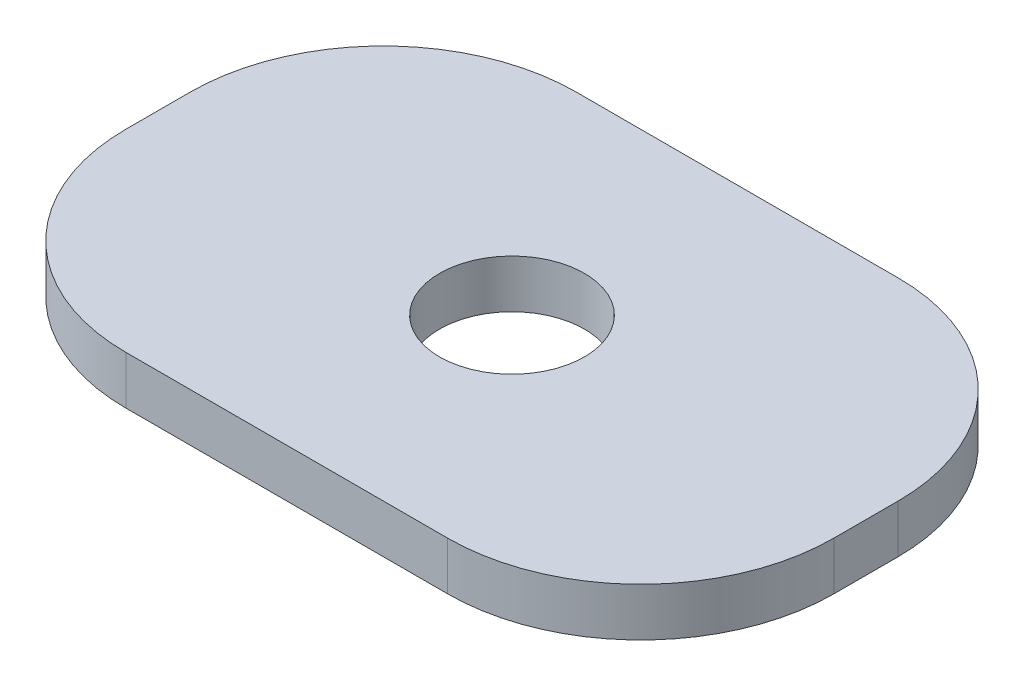
from build123d import *

# Parameters (mm, degrees)
SKETCH1_W           = 69.85
SKETCH1_H           = 44.45
BOSS_EXTRUDE1_DEPTH = 4.7625
SKETCH2_R           = 7.14375
CUT_EXTRUDE1_DEPTH  = 5.7625
FILLET1_R           = 19.05
FILLET2_R           = 19.05


with BuildPart() as part:
    # Sketch1 → Boss-Extrude1 (new body)
    with BuildSketch(Plane(origin=(0, 0, 0), x_dir=(1, 0, 0), z_dir=(0, 1, 0))):
        Rectangle(SKETCH1_W, SKETCH1_H)
    extrude(amount=BOSS_EXTRUDE1_DEPTH)

    # Sketch2 → Cut-Extrude1 (cut, through all)
    with BuildSketch(Plane(origin=(0, 4.7625, 0), x_dir=(1, 0, 0), z_dir=(0, 1, 0))):
        Circle(SKETCH2_R)
    extrude(amount=-CUT_EXTRUDE1_DEPTH, mode=Mode.SUBTRACT)

    # Fillet1
    fillet1_edges = [part.edges().sort_by_distance(p)[0] for p in [
        (-34.925, 2.38125, 22.225),
        (-34.925, 2.38125, -22.225),
    ]]
    fillet(fillet1_edges, radius=FILLET1_R)

    # Fillet2
    fillet2_edges = [part.edges().sort_by_distance(p)[0] for p in [
        (34.925, 2.38125, 22.225),
        (34.925, 2.38125, -22.225),
    ]]
    fillet(fillet2_edges, radius=FILLET2_R)


solid = part.part
